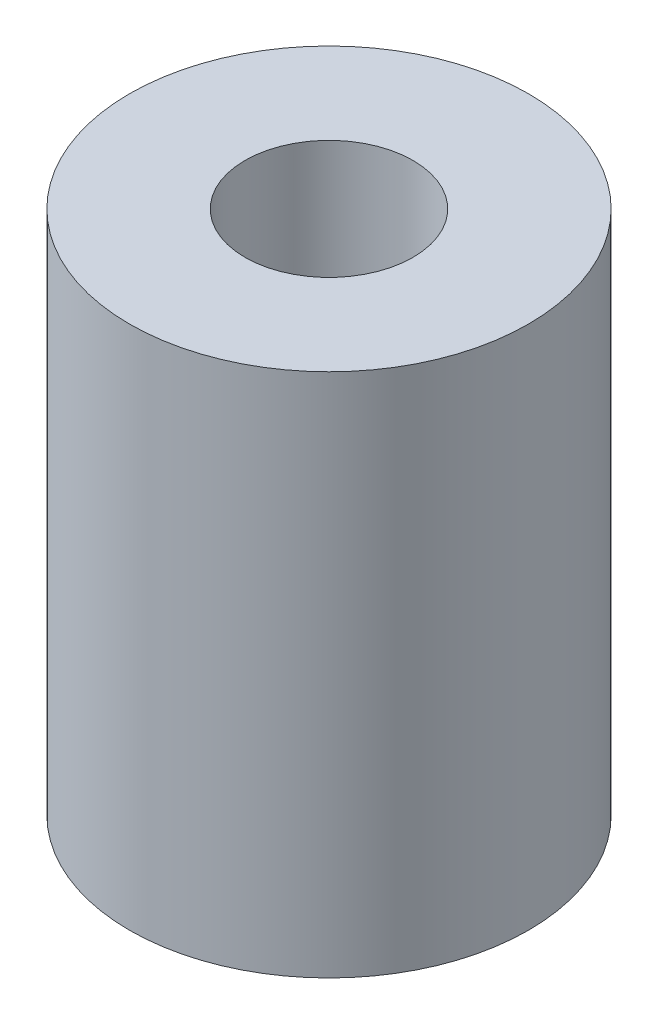
from build123d import *

# Parameters (mm, degrees)
CROQUIS1_R              = 9.5
SALIENTE_EXTRUIR1_DEPTH = 25
CROQUIS2_R              = 4
CORTAR_EXTRUIR1_DEPTH   = 17
CROQUIS3_R              = 2.5
CORTAR_EXTRUIR2_DEPTH   = 8


with BuildPart() as part:
    # Croquis1 → Saliente-Extruir1 (new body)
    with BuildSketch(Plane(origin=(0, 0, 0), x_dir=(1, 0, 0), z_dir=(0, 1, 0))):
        Circle(CROQUIS1_R)
    extrude(amount=SALIENTE_EXTRUIR1_DEPTH)

    # Croquis2 → Cortar-Extruir1 (cut)
    with BuildSketch(Plane(origin=(0, 25, 0), x_dir=(1, 0, 0), z_dir=(0, 1, 0))):
        Circle(CROQUIS2_R)
    extrude(amount=-CORTAR_EXTRUIR1_DEPTH, mode=Mode.SUBTRACT)

    # Croquis3 → Cortar-Extruir2 (cut)
    with BuildSketch(Plane.XZ):
        Circle(CROQUIS3_R)
    extrude(amount=-CORTAR_EXTRUIR2_DEPTH, mode=Mode.SUBTRACT)


solid = part.part
